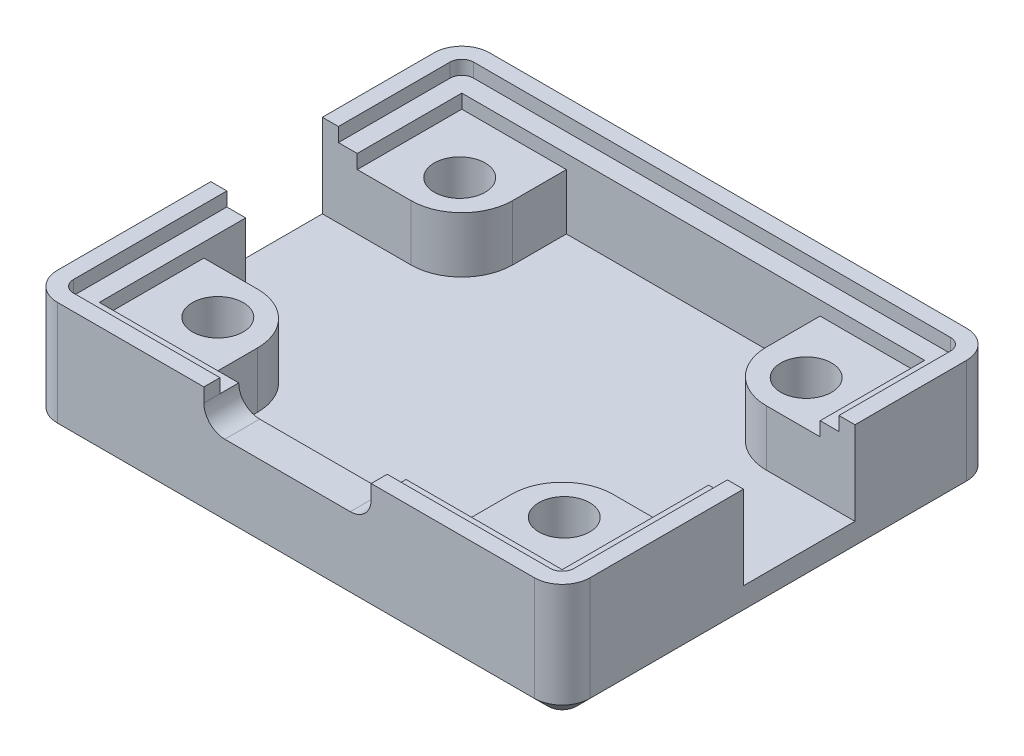
from build123d import *

# Parameters (mm, degrees)
BOSS_EXTRUDE1_DEPTH = 7.5
CUT_EXTRUDE3_DEPTH  = 5
SKETCH3_R           = 1.825
CUT_EXTRUDE4_DEPTH  = 13.5
SKETCH4_W           = 33.2
SKETCH4_H           = 26
CUT_EXTRUDE5_DEPTH  = 1
SKETCH5_W           = 2.5
SKETCH5_H           = 8
CUT_EXTRUDE6_DEPTH  = 5
BOSS_EXTRUDE2_DEPTH = 1
CUT_EXTRUDE8_DEPTH  = 10
SKETCH9_W           = 0.917517868
SKETCH9_H           = 1.289779541
SKETCH9_W_2         = 0.704402717
CUT_EXTRUDE9_DEPTH  = 1
CHAMFER1_SIZE       = 1
FILLET1_R           = 3.65


with BuildPart() as part:
    # Sketch1 → Boss-Extrude1 (new body)
    with BuildSketch(Plane(origin=(0, 0, 0), x_dir=(1, 0, 0), z_dir=(0, 1, 0))):
        with BuildLine():
            Line((-17.1, -15.5), (17.1, -15.5))
            ThreePointArc((17.1, -15.5), (18.514213562, -14.914213562), (19.1, -13.5))
            Line((19.1, -13.5), (19.1, 13.5))
            ThreePointArc((19.1, 13.5), (18.514213562, 14.914213562), (17.1, 15.5))
            Line((17.1, 15.5), (-17.1, 15.5))
            ThreePointArc((-17.1, 15.5), (-18.514213562, 14.914213562), (-19.1, 13.5))
            Line((-19.1, 13.5), (-19.1, -13.5))
            ThreePointArc((-19.1, -13.5), (-18.514213562, -14.914213562), (-17.1, -15.5))
        make_face()
    extrude(amount=BOSS_EXTRUDE1_DEPTH)

    # Sketch2 → Cut-Extrude3 (cut)
    with BuildSketch(Plane(origin=(0, 7.5, 0), x_dir=(1, 0, 0), z_dir=(0, 1, 0))):
        Polygon((-16.6, 5.5), (-9.1, 5.5), (-9.1, 13), (9.1, 13), (9.1, 5.5), (16.6, 5.5), (16.6, -5.5), (9.1, -5.5), (9.1, -13), (-9.1, -13), (-9.1, -5.5), (-16.6, -5.5), align=None)
    extrude(amount=-CUT_EXTRUDE3_DEPTH, mode=Mode.SUBTRACT)

    # Sketch3 → Cut-Extrude4 (cut)
    with BuildSketch(Plane(origin=(0, 7.5, 0), x_dir=(1, 0, 0), z_dir=(0, 1, 0))):
        with Locations((-12.425, 8.675)):
            Circle(SKETCH3_R)
        with Locations((12.425, 8.675)):
            Circle(SKETCH3_R)
        with Locations((12.425, -8.675)):
            Circle(SKETCH3_R)
        with Locations((-12.425, -8.675)):
            Circle(SKETCH3_R)
    extrude(amount=-CUT_EXTRUDE4_DEPTH, mode=Mode.SUBTRACT)

    # Sketch4 → Cut-Extrude5 (cut)
    with BuildSketch(Plane(origin=(0, 7.5, 0), x_dir=(1, 0, 0), z_dir=(0, 1, 0))):
        Rectangle(SKETCH4_W, SKETCH4_H)
    extrude(amount=-CUT_EXTRUDE5_DEPTH, mode=Mode.SUBTRACT)

    # Sketch5 → Cut-Extrude6 (cut)
    with BuildSketch(Plane(origin=(0, 7.5, 0), x_dir=(1, 0, 0), z_dir=(0, 1, 0))):
        with Locations((-17.85, 1.5)):
            Rectangle(SKETCH5_W, SKETCH5_H)
        with Locations((17.85, 1.5)):
            Rectangle(SKETCH5_W, SKETCH5_H)
    extrude(amount=-CUT_EXTRUDE6_DEPTH, mode=Mode.SUBTRACT)

    # Sketch6 → Boss-Extrude2 (add)
    with BuildSketch(Plane(origin=(0, 7.5, 0), x_dir=(1, 0, 0), z_dir=(0, 1, 0))):
        with BuildLine():
            Line((-17.95, 5.5), (-19.1, 5.5))
            Line((-19.1, 5.5), (-19.1, 13.5))
            ThreePointArc((-19.1, 13.5), (-18.514213562, 14.914213562), (-17.1, 15.5))
            Line((-17.1, 15.5), (17.1, 15.5))
            ThreePointArc((17.1, 15.5), (18.514213562, 14.914213562), (19.1, 13.5))
            Line((19.1, 13.5), (19.1, 5.5))
            Line((19.1, 5.5), (17.95, 5.5))
            Line((17.95, 5.5), (17.95, 13.5))
            ThreePointArc((17.95, 13.5), (17.701040764, 14.101040764), (17.1, 14.35))
            Line((17.1, 14.35), (-17.1, 14.35))
            ThreePointArc((-17.1, 14.35), (-17.701040764, 14.101040764), (-17.95, 13.5))
            Line((-17.95, 13.5), (-17.95, 5.5))
        make_face()
        with BuildLine():
            Line((-17.95, -2.5), (-19.1, -2.5))
            Line((-19.1, -2.5), (-19.1, -13.5))
            ThreePointArc((-19.1, -13.5), (-18.514213562, -14.914213562), (-17.1, -15.5))
            Line((-17.1, -15.5), (17.1, -15.5))
            ThreePointArc((17.1, -15.5), (18.514213562, -14.914213562), (19.1, -13.5))
            Line((19.1, -13.5), (19.1, -2.5))
            Line((19.1, -2.5), (17.95, -2.5))
            Line((17.95, -2.5), (17.95, -13.5))
            ThreePointArc((17.95, -13.5), (17.701040764, -14.101040764), (17.1, -14.35))
            Line((17.1, -14.35), (-17.1, -14.35))
            ThreePointArc((-17.1, -14.35), (-17.701040764, -14.101040764), (-17.95, -13.5))
            Line((-17.95, -13.5), (-17.95, -2.5))
        make_face()
    extrude(amount=BOSS_EXTRUDE2_DEPTH)

    # Sketch7 → Cut-Extrude8 (cut)
    with BuildSketch(Plane.XY.offset(15.5)):
        with BuildLine():
            Line((-5.1, 9), (3.9, 9))
            ThreePointArc((3.9, 9), (5.4, 7.5), (3.9, 6))
            Line((3.9, 6), (-5.1, 6))
            ThreePointArc((-5.1, 6), (-6.6, 7.5), (-5.1, 9))
        make_face()
    extrude(amount=-CUT_EXTRUDE8_DEPTH, mode=Mode.SUBTRACT)

    # Sketch9 → Cut-Extrude9 (cut)
    with BuildSketch(Plane(origin=(0, 7.5, 0), x_dir=(1, 0, 0), z_dir=(0, 1, 0))):
        with Locations((-6.141241066, -14.994889771)):
            Rectangle(SKETCH9_W, SKETCH9_H)
        with Locations((5.047798642, -14.994889771)):
            Rectangle(SKETCH9_W_2, SKETCH9_H)
    extrude(amount=CUT_EXTRUDE9_DEPTH, mode=Mode.SUBTRACT)

    # Chamfer1
    chamfer1_edges = [part.edges().sort_by_distance(p)[0] for p in [
        (-19.1, 0, 0),
        (-18.514213562, 0, -14.914213562),
        (0, 0, -15.5),
        (18.514213562, 0, -14.914213562),
        (19.1, 0, 0),
        (18.514213562, 0, 14.914213562),
        (0, 0, 15.5),
        (-18.514213562, 0, 14.914213562),
    ]]
    chamfer(chamfer1_edges, length=CHAMFER1_SIZE)

    # Fillet1
    fillet1_edges = [part.edges().sort_by_distance(p)[0] for p in [
        (-9.1, 4.5, 5.5),
        (-9.1, 4.5, -5.5),
        (9.1, 4.5, -5.5),
        (9.1, 4.5, 5.5),
    ]]
    fillet(fillet1_edges, radius=FILLET1_R)


solid = part.part
